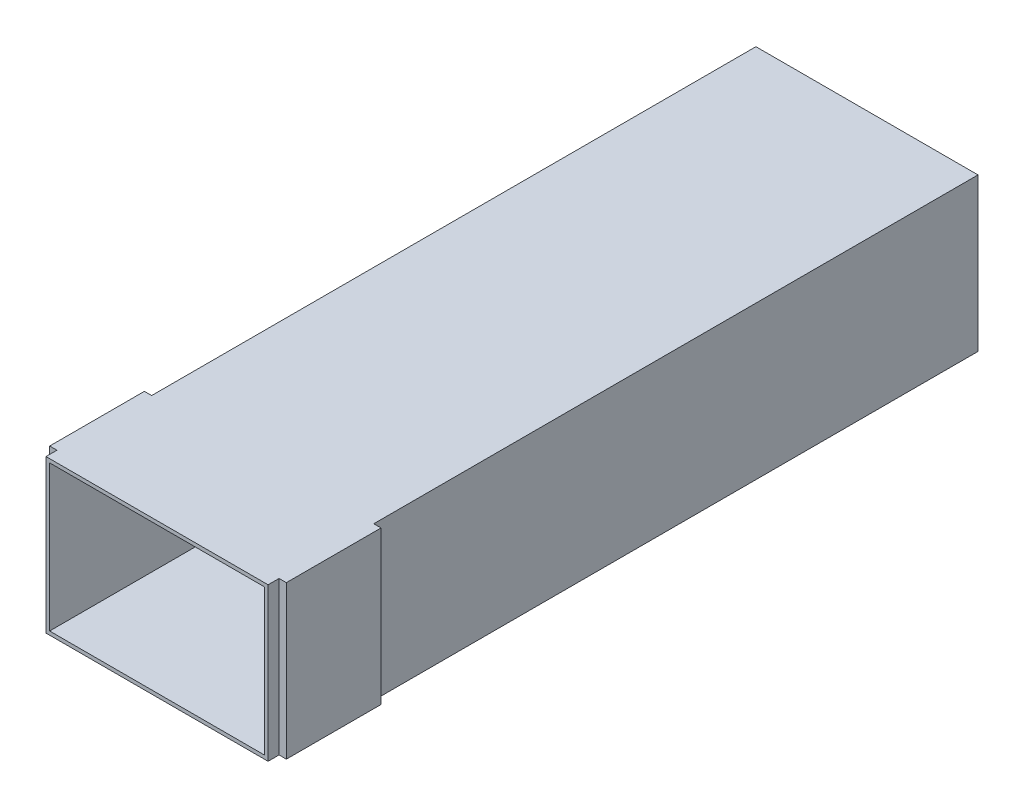
from build123d import *

# Parameters (mm, degrees)
SKETCH1_W           = 15.25
SKETCH1_H           = 48.75
BOSS_EXTRUDE1_DEPTH = 10.5
SHELL1_T            = -0.25
SKETCH3_W           = 6.5
SKETCH3_H           = 10.5
BOSS_EXTRUDE2_DEPTH = 0.5


with BuildPart() as part:
    # Sketch1 → Boss-Extrude1 (new body)
    with BuildSketch(Plane(origin=(0, 0, 0), x_dir=(1, 0, 0), z_dir=(0, 1, 0))):
        with Locations((-7.625, -16.379710312)):
            Rectangle(SKETCH1_W, SKETCH1_H)
    extrude(amount=BOSS_EXTRUDE1_DEPTH)

    # Shell1
    shell1_openings = [part.faces().sort_by_distance(p)[0] for p in [
        (-7.625, 5.25, 40.754710312),
    ]]
    offset(amount=SHELL1_T, openings=shell1_openings, kind=Kind.INTERSECTION)

    # Sketch3 → Boss-Extrude2 (add)
    with BuildSketch(Plane(origin=(0, 0, 0), x_dir=(0, 0, -1), z_dir=(1, 0, 0))):
        with Locations((-36.75, 5.25)):
            Rectangle(SKETCH3_W, SKETCH3_H)
    boss_extrude2 = extrude(amount=BOSS_EXTRUDE2_DEPTH)

    # Mirror1: Boss-Extrude2 across plane
    add(boss_extrude2.mirror(Plane.ZY.offset(7.625)))


solid = part.part
